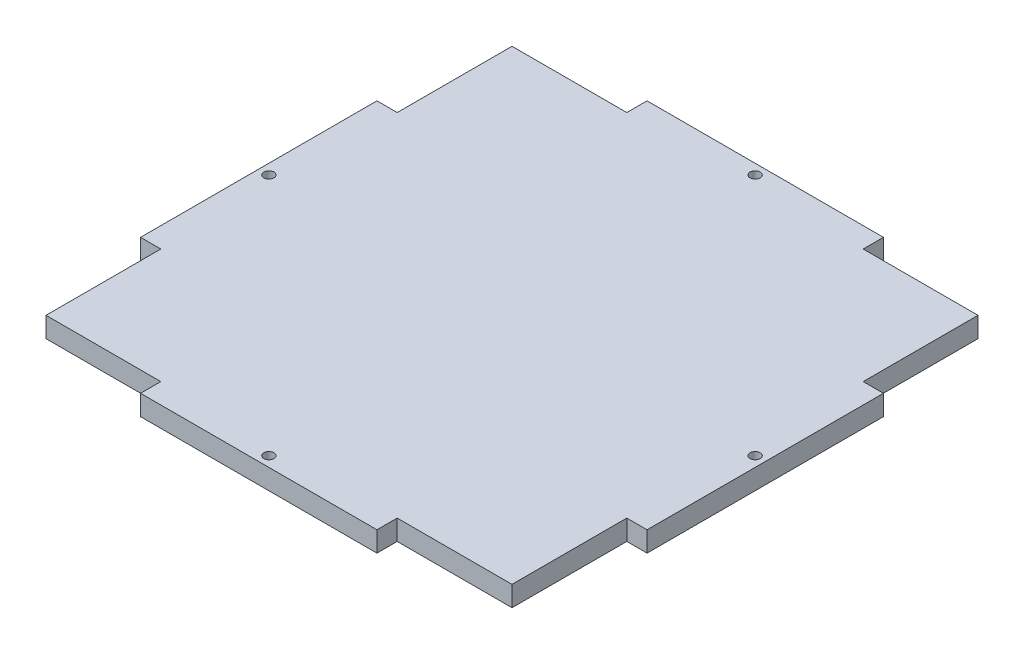
from build123d import *

# Parameters (mm, degrees)
SKETCH1_R           = 1.5
BOSS_EXTRUDE1_DEPTH = 6


with BuildPart() as part:
    # Sketch1 → Boss-Extrude1 (new body)
    with BuildSketch(Plane(origin=(0, 0, 0), x_dir=(1, 0, 0), z_dir=(0, 1, 0))):
        Polygon((69, 69), (35, 69), (35, 75), (-35, 75), (-35, 69), (-69, 69), (-69, 35), (-75, 35), (-75, -35), (-69, -35), (-69, -69), (-35, -69), (-35, -75), (35, -75), (35, -69), (69, -69), (69, -35), (75, -35), (75, 35), (69, 35), align=None)
        with Locations((0, 72)):
            Circle(SKETCH1_R, mode=Mode.SUBTRACT)
        with Locations((-72, 0)):
            Circle(SKETCH1_R, mode=Mode.SUBTRACT)
        with Locations((72, 0)):
            Circle(SKETCH1_R, mode=Mode.SUBTRACT)
        with Locations((0, -72)):
            Circle(SKETCH1_R, mode=Mode.SUBTRACT)
    extrude(amount=BOSS_EXTRUDE1_DEPTH)


solid = part.part
